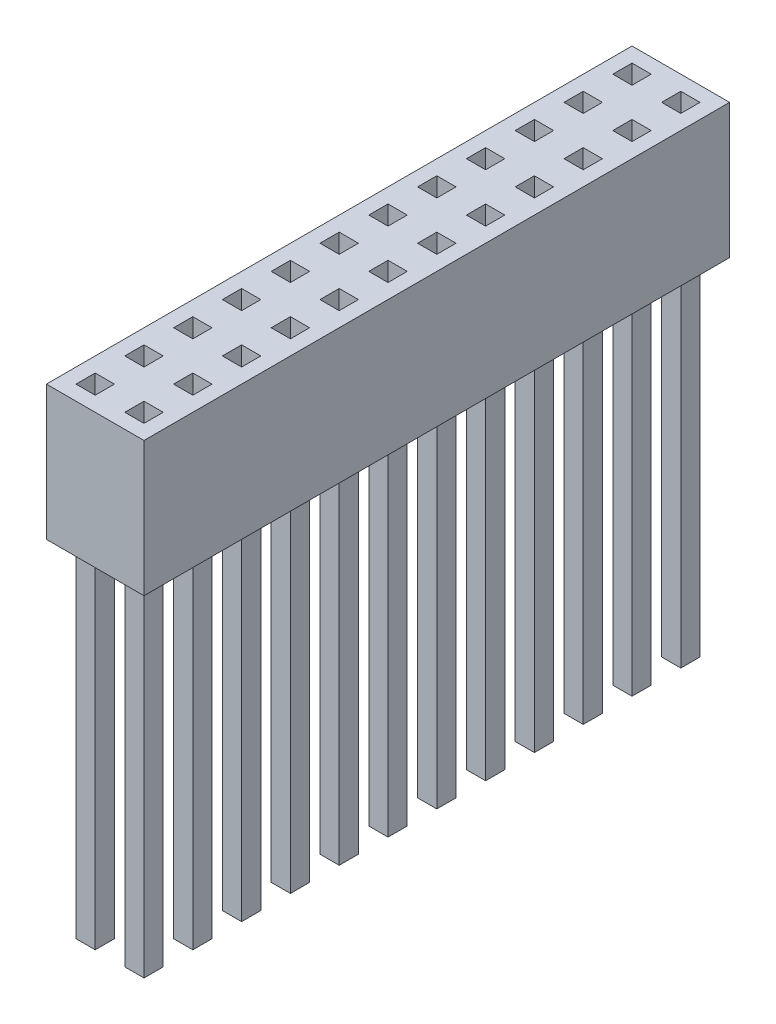
from build123d import *

# Parameters (mm, degrees)
SKETCH_1_W              = 1
SKETCH_1_H              = 1
EXTRUDE_1_DEPTH         = 20
EXTRUDE_1_DEPTH_BACK    = 4
EXTRUDE_1_2_DEPTH       = 20
EXTRUDE_1_2_DEPTH_BACK  = 4
EXTRUDE_1_3_DEPTH       = 20
EXTRUDE_1_3_DEPTH_BACK  = 4
EXTRUDE_1_4_DEPTH       = 20
EXTRUDE_1_4_DEPTH_BACK  = 4
EXTRUDE_1_5_DEPTH       = 20
EXTRUDE_1_5_DEPTH_BACK  = 4
EXTRUDE_1_6_DEPTH       = 20
EXTRUDE_1_6_DEPTH_BACK  = 4
EXTRUDE_1_7_DEPTH       = 20
EXTRUDE_1_7_DEPTH_BACK  = 4
EXTRUDE_1_8_DEPTH       = 20
EXTRUDE_1_8_DEPTH_BACK  = 4
EXTRUDE_1_9_DEPTH       = 20
EXTRUDE_1_9_DEPTH_BACK  = 4
EXTRUDE_1_10_DEPTH      = 20
EXTRUDE_1_10_DEPTH_BACK = 4
EXTRUDE_1_11_DEPTH      = 20
EXTRUDE_1_11_DEPTH_BACK = 4
EXTRUDE_1_12_DEPTH      = 20
EXTRUDE_1_12_DEPTH_BACK = 4
EXTRUDE_1_13_DEPTH      = 20
EXTRUDE_1_13_DEPTH_BACK = 4
EXTRUDE_1_14_DEPTH      = 20
EXTRUDE_1_14_DEPTH_BACK = 4
EXTRUDE_1_15_DEPTH      = 20
EXTRUDE_1_15_DEPTH_BACK = 4
EXTRUDE_1_16_DEPTH      = 20
EXTRUDE_1_16_DEPTH_BACK = 4
EXTRUDE_1_17_DEPTH      = 20
EXTRUDE_1_17_DEPTH_BACK = 4
EXTRUDE_1_18_DEPTH      = 20
EXTRUDE_1_18_DEPTH_BACK = 4
EXTRUDE_1_19_DEPTH      = 20
EXTRUDE_1_19_DEPTH_BACK = 4
EXTRUDE_1_20_DEPTH      = 20
EXTRUDE_1_20_DEPTH_BACK = 4
EXTRUDE_1_21_DEPTH      = 20
EXTRUDE_1_21_DEPTH_BACK = 4
EXTRUDE_1_22_DEPTH      = 20
EXTRUDE_1_22_DEPTH_BACK = 4
EXTRUDE_1_23_DEPTH      = 20
EXTRUDE_1_23_DEPTH_BACK = 4
EXTRUDE_1_24_DEPTH      = 20
EXTRUDE_1_24_DEPTH_BACK = 4
SKETCH_2_W              = 5.08
SKETCH_2_H              = 30.48
SKETCH_2_W_2            = 1
SKETCH_2_H_2            = 1
EXTRUDE_2_DEPTH         = 1
EXTRUDE_2_DEPTH_BACK    = 6


with BuildPart() as part:
    # Эскиз1 → Бобышка-Вытянуть1 (new body, two sides)
    with BuildSketch(Plane(origin=(0, 0, 0), x_dir=(1, 0, 0), z_dir=(0, 1, 0))) as extrude_1_sk:
        with Locations((2.54, 0)):
            Rectangle(SKETCH_1_W, SKETCH_1_H)
    extrude(amount=EXTRUDE_1_DEPTH)
    extrude(extrude_1_sk.sketch, amount=-EXTRUDE_1_DEPTH_BACK)



with BuildPart() as body_2:
    # Эскиз1 → Extrude 1 2 (new body, two sides)
    with BuildSketch(Plane(origin=(0, 0, 0), x_dir=(1, 0, 0), z_dir=(0, 1, 0))) as extrude_1_2_sk:
        Rectangle(SKETCH_1_W, SKETCH_1_H)
    extrude(amount=EXTRUDE_1_2_DEPTH)
    extrude(extrude_1_2_sk.sketch, amount=-EXTRUDE_1_2_DEPTH_BACK)


with BuildPart() as body_3:
    # Эскиз1 → Extrude 1 3 (new body, two sides)
    with BuildSketch(Plane(origin=(0, 0, 0), x_dir=(1, 0, 0), z_dir=(0, 1, 0))) as extrude_1_3_sk:
        with Locations((2.54, 2.54)):
            Rectangle(SKETCH_1_W, SKETCH_1_H)
    extrude(amount=EXTRUDE_1_3_DEPTH)
    extrude(extrude_1_3_sk.sketch, amount=-EXTRUDE_1_3_DEPTH_BACK)


with BuildPart() as body_4:
    # Эскиз1 → Extrude 1 4 (new body, two sides)
    with BuildSketch(Plane(origin=(0, 0, 0), x_dir=(1, 0, 0), z_dir=(0, 1, 0))) as extrude_1_4_sk:
        with Locations((2.54, 5.08)):
            Rectangle(SKETCH_1_W, SKETCH_1_H)
    extrude(amount=EXTRUDE_1_4_DEPTH)
    extrude(extrude_1_4_sk.sketch, amount=-EXTRUDE_1_4_DEPTH_BACK)


with BuildPart() as body_5:
    # Эскиз1 → Extrude 1 5 (new body, two sides)
    with BuildSketch(Plane(origin=(0, 0, 0), x_dir=(1, 0, 0), z_dir=(0, 1, 0))) as extrude_1_5_sk:
        with Locations((2.54, 7.62)):
            Rectangle(SKETCH_1_W, SKETCH_1_H)
    extrude(amount=EXTRUDE_1_5_DEPTH)
    extrude(extrude_1_5_sk.sketch, amount=-EXTRUDE_1_5_DEPTH_BACK)


with BuildPart() as body_6:
    # Эскиз1 → Extrude 1 6 (new body, two sides)
    with BuildSketch(Plane(origin=(0, 0, 0), x_dir=(1, 0, 0), z_dir=(0, 1, 0))) as extrude_1_6_sk:
        with Locations((2.54, 10.16)):
            Rectangle(SKETCH_1_W, SKETCH_1_H)
    extrude(amount=EXTRUDE_1_6_DEPTH)
    extrude(extrude_1_6_sk.sketch, amount=-EXTRUDE_1_6_DEPTH_BACK)


with BuildPart() as body_7:
    # Эскиз1 → Extrude 1 7 (new body, two sides)
    with BuildSketch(Plane(origin=(0, 0, 0), x_dir=(1, 0, 0), z_dir=(0, 1, 0))) as extrude_1_7_sk:
        with Locations((2.54, 12.7)):
            Rectangle(SKETCH_1_W, SKETCH_1_H)
    extrude(amount=EXTRUDE_1_7_DEPTH)
    extrude(extrude_1_7_sk.sketch, amount=-EXTRUDE_1_7_DEPTH_BACK)


with BuildPart() as body_8:
    # Эскиз1 → Extrude 1 8 (new body, two sides)
    with BuildSketch(Plane(origin=(0, 0, 0), x_dir=(1, 0, 0), z_dir=(0, 1, 0))) as extrude_1_8_sk:
        with Locations((2.54, 15.24)):
            Rectangle(SKETCH_1_W, SKETCH_1_H)
    extrude(amount=EXTRUDE_1_8_DEPTH)
    extrude(extrude_1_8_sk.sketch, amount=-EXTRUDE_1_8_DEPTH_BACK)


with BuildPart() as body_9:
    # Эскиз1 → Extrude 1 9 (new body, two sides)
    with BuildSketch(Plane(origin=(0, 0, 0), x_dir=(1, 0, 0), z_dir=(0, 1, 0))) as extrude_1_9_sk:
        with Locations((2.54, 17.78)):
            Rectangle(SKETCH_1_W, SKETCH_1_H)
    extrude(amount=EXTRUDE_1_9_DEPTH)
    extrude(extrude_1_9_sk.sketch, amount=-EXTRUDE_1_9_DEPTH_BACK)


with BuildPart() as body_10:
    # Эскиз1 → Extrude 1 10 (new body, two sides)
    with BuildSketch(Plane(origin=(0, 0, 0), x_dir=(1, 0, 0), z_dir=(0, 1, 0))) as extrude_1_10_sk:
        with Locations((2.54, 20.32)):
            Rectangle(SKETCH_1_W, SKETCH_1_H)
    extrude(amount=EXTRUDE_1_10_DEPTH)
    extrude(extrude_1_10_sk.sketch, amount=-EXTRUDE_1_10_DEPTH_BACK)


with BuildPart() as body_11:
    # Эскиз1 → Extrude 1 11 (new body, two sides)
    with BuildSketch(Plane(origin=(0, 0, 0), x_dir=(1, 0, 0), z_dir=(0, 1, 0))) as extrude_1_11_sk:
        with Locations((2.54, 22.86)):
            Rectangle(SKETCH_1_W, SKETCH_1_H)
    extrude(amount=EXTRUDE_1_11_DEPTH)
    extrude(extrude_1_11_sk.sketch, amount=-EXTRUDE_1_11_DEPTH_BACK)


with BuildPart() as body_12:
    # Эскиз1 → Extrude 1 12 (new body, two sides)
    with BuildSketch(Plane(origin=(0, 0, 0), x_dir=(1, 0, 0), z_dir=(0, 1, 0))) as extrude_1_12_sk:
        with Locations((2.54, 25.4)):
            Rectangle(SKETCH_1_W, SKETCH_1_H)
    extrude(amount=EXTRUDE_1_12_DEPTH)
    extrude(extrude_1_12_sk.sketch, amount=-EXTRUDE_1_12_DEPTH_BACK)


with BuildPart() as body_13:
    # Эскиз1 → Extrude 1 13 (new body, two sides)
    with BuildSketch(Plane(origin=(0, 0, 0), x_dir=(1, 0, 0), z_dir=(0, 1, 0))) as extrude_1_13_sk:
        with Locations((2.54, 27.94)):
            Rectangle(SKETCH_1_W, SKETCH_1_H)
    extrude(amount=EXTRUDE_1_13_DEPTH)
    extrude(extrude_1_13_sk.sketch, amount=-EXTRUDE_1_13_DEPTH_BACK)


with BuildPart() as body_14:
    # Эскиз1 → Extrude 1 14 (new body, two sides)
    with BuildSketch(Plane(origin=(0, 0, 0), x_dir=(1, 0, 0), z_dir=(0, 1, 0))) as extrude_1_14_sk:
        with Locations((0, 2.54)):
            Rectangle(SKETCH_1_W, SKETCH_1_H)
    extrude(amount=EXTRUDE_1_14_DEPTH)
    extrude(extrude_1_14_sk.sketch, amount=-EXTRUDE_1_14_DEPTH_BACK)


with BuildPart() as body_15:
    # Эскиз1 → Extrude 1 15 (new body, two sides)
    with BuildSketch(Plane(origin=(0, 0, 0), x_dir=(1, 0, 0), z_dir=(0, 1, 0))) as extrude_1_15_sk:
        with Locations((0, 5.08)):
            Rectangle(SKETCH_1_W, SKETCH_1_H)
    extrude(amount=EXTRUDE_1_15_DEPTH)
    extrude(extrude_1_15_sk.sketch, amount=-EXTRUDE_1_15_DEPTH_BACK)


with BuildPart() as body_16:
    # Эскиз1 → Extrude 1 16 (new body, two sides)
    with BuildSketch(Plane(origin=(0, 0, 0), x_dir=(1, 0, 0), z_dir=(0, 1, 0))) as extrude_1_16_sk:
        with Locations((0, 7.62)):
            Rectangle(SKETCH_1_W, SKETCH_1_H)
    extrude(amount=EXTRUDE_1_16_DEPTH)
    extrude(extrude_1_16_sk.sketch, amount=-EXTRUDE_1_16_DEPTH_BACK)


with BuildPart() as body_17:
    # Эскиз1 → Extrude 1 17 (new body, two sides)
    with BuildSketch(Plane(origin=(0, 0, 0), x_dir=(1, 0, 0), z_dir=(0, 1, 0))) as extrude_1_17_sk:
        with Locations((0, 10.16)):
            Rectangle(SKETCH_1_W, SKETCH_1_H)
    extrude(amount=EXTRUDE_1_17_DEPTH)
    extrude(extrude_1_17_sk.sketch, amount=-EXTRUDE_1_17_DEPTH_BACK)


with BuildPart() as body_18:
    # Эскиз1 → Extrude 1 18 (new body, two sides)
    with BuildSketch(Plane(origin=(0, 0, 0), x_dir=(1, 0, 0), z_dir=(0, 1, 0))) as extrude_1_18_sk:
        with Locations((0, 12.7)):
            Rectangle(SKETCH_1_W, SKETCH_1_H)
    extrude(amount=EXTRUDE_1_18_DEPTH)
    extrude(extrude_1_18_sk.sketch, amount=-EXTRUDE_1_18_DEPTH_BACK)


with BuildPart() as body_19:
    # Эскиз1 → Extrude 1 19 (new body, two sides)
    with BuildSketch(Plane(origin=(0, 0, 0), x_dir=(1, 0, 0), z_dir=(0, 1, 0))) as extrude_1_19_sk:
        with Locations((0, 15.24)):
            Rectangle(SKETCH_1_W, SKETCH_1_H)
    extrude(amount=EXTRUDE_1_19_DEPTH)
    extrude(extrude_1_19_sk.sketch, amount=-EXTRUDE_1_19_DEPTH_BACK)


with BuildPart() as body_20:
    # Эскиз1 → Extrude 1 20 (new body, two sides)
    with BuildSketch(Plane(origin=(0, 0, 0), x_dir=(1, 0, 0), z_dir=(0, 1, 0))) as extrude_1_20_sk:
        with Locations((0, 17.78)):
            Rectangle(SKETCH_1_W, SKETCH_1_H)
    extrude(amount=EXTRUDE_1_20_DEPTH)
    extrude(extrude_1_20_sk.sketch, amount=-EXTRUDE_1_20_DEPTH_BACK)


with BuildPart() as body_21:
    # Эскиз1 → Extrude 1 21 (new body, two sides)
    with BuildSketch(Plane(origin=(0, 0, 0), x_dir=(1, 0, 0), z_dir=(0, 1, 0))) as extrude_1_21_sk:
        with Locations((0, 20.32)):
            Rectangle(SKETCH_1_W, SKETCH_1_H)
    extrude(amount=EXTRUDE_1_21_DEPTH)
    extrude(extrude_1_21_sk.sketch, amount=-EXTRUDE_1_21_DEPTH_BACK)


with BuildPart() as body_22:
    # Эскиз1 → Extrude 1 22 (new body, two sides)
    with BuildSketch(Plane(origin=(0, 0, 0), x_dir=(1, 0, 0), z_dir=(0, 1, 0))) as extrude_1_22_sk:
        with Locations((0, 22.86)):
            Rectangle(SKETCH_1_W, SKETCH_1_H)
    extrude(amount=EXTRUDE_1_22_DEPTH)
    extrude(extrude_1_22_sk.sketch, amount=-EXTRUDE_1_22_DEPTH_BACK)


with BuildPart() as body_23:
    # Эскиз1 → Extrude 1 23 (new body, two sides)
    with BuildSketch(Plane(origin=(0, 0, 0), x_dir=(1, 0, 0), z_dir=(0, 1, 0))) as extrude_1_23_sk:
        with Locations((0, 25.4)):
            Rectangle(SKETCH_1_W, SKETCH_1_H)
    extrude(amount=EXTRUDE_1_23_DEPTH)
    extrude(extrude_1_23_sk.sketch, amount=-EXTRUDE_1_23_DEPTH_BACK)


with BuildPart() as body_24:
    # Эскиз1 → Extrude 1 24 (new body, two sides)
    with BuildSketch(Plane(origin=(0, 0, 0), x_dir=(1, 0, 0), z_dir=(0, 1, 0))) as extrude_1_24_sk:
        with Locations((0, 27.94)):
            Rectangle(SKETCH_1_W, SKETCH_1_H)
    extrude(amount=EXTRUDE_1_24_DEPTH)
    extrude(extrude_1_24_sk.sketch, amount=-EXTRUDE_1_24_DEPTH_BACK)


with BuildPart() as part_1:
    add(part.part)

    add(body_2.part)  # Бобышка-Вытянуть2 merges body 2

    add(body_3.part)  # Бобышка-Вытянуть2 merges body 3

    add(body_4.part)  # Бобышка-Вытянуть2 merges body 4

    add(body_5.part)  # Бобышка-Вытянуть2 merges body 5

    add(body_6.part)  # Бобышка-Вытянуть2 merges body 6

    add(body_7.part)  # Бобышка-Вытянуть2 merges body 7

    add(body_8.part)  # Бобышка-Вытянуть2 merges body 8

    add(body_9.part)  # Бобышка-Вытянуть2 merges body 9

    add(body_10.part)  # Бобышка-Вытянуть2 merges body 10

    add(body_11.part)  # Бобышка-Вытянуть2 merges body 11

    add(body_12.part)  # Бобышка-Вытянуть2 merges body 12

    add(body_13.part)  # Бобышка-Вытянуть2 merges body 13

    add(body_14.part)  # Бобышка-Вытянуть2 merges body 14

    add(body_15.part)  # Бобышка-Вытянуть2 merges body 15

    add(body_16.part)  # Бобышка-Вытянуть2 merges body 16

    add(body_17.part)  # Бобышка-Вытянуть2 merges body 17

    add(body_18.part)  # Бобышка-Вытянуть2 merges body 18

    add(body_19.part)  # Бобышка-Вытянуть2 merges body 19

    add(body_20.part)  # Бобышка-Вытянуть2 merges body 20

    add(body_21.part)  # Бобышка-Вытянуть2 merges body 21

    add(body_22.part)  # Бобышка-Вытянуть2 merges body 22

    add(body_23.part)  # Бобышка-Вытянуть2 merges body 23

    add(body_24.part)  # Бобышка-Вытянуть2 merges body 24
    # Эскиз2 → Бобышка-Вытянуть2 (add, two sides)
    with BuildSketch(Plane(origin=(0, 20, 0), x_dir=(1, 0, 0), z_dir=(0, 1, 0))) as extrude_2_sk:
        with Locations((1.27, 13.97)):
            Rectangle(SKETCH_2_W, SKETCH_2_H)
        with Locations((2.54, 0)):
            Rectangle(SKETCH_2_W_2, SKETCH_2_H_2, mode=Mode.SUBTRACT)
        Rectangle(SKETCH_2_W_2, SKETCH_2_H_2, mode=Mode.SUBTRACT)
        with Locations((2.54, 2.54)):
            Rectangle(SKETCH_2_W_2, SKETCH_2_H_2, mode=Mode.SUBTRACT)
        with Locations((2.54, 5.08)):
            Rectangle(SKETCH_2_W_2, SKETCH_2_H_2, mode=Mode.SUBTRACT)
        with Locations((2.54, 7.62)):
            Rectangle(SKETCH_2_W_2, SKETCH_2_H_2, mode=Mode.SUBTRACT)
        with Locations((2.54, 10.16)):
            Rectangle(SKETCH_2_W_2, SKETCH_2_H_2, mode=Mode.SUBTRACT)
        with Locations((2.54, 12.7)):
            Rectangle(SKETCH_2_W_2, SKETCH_2_H_2, mode=Mode.SUBTRACT)
        with Locations((2.54, 15.24)):
            Rectangle(SKETCH_2_W_2, SKETCH_2_H_2, mode=Mode.SUBTRACT)
        with Locations((2.54, 17.78)):
            Rectangle(SKETCH_2_W_2, SKETCH_2_H_2, mode=Mode.SUBTRACT)
        with Locations((2.54, 20.32)):
            Rectangle(SKETCH_2_W_2, SKETCH_2_H_2, mode=Mode.SUBTRACT)
        with Locations((2.54, 22.86)):
            Rectangle(SKETCH_2_W_2, SKETCH_2_H_2, mode=Mode.SUBTRACT)
        with Locations((2.54, 25.4)):
            Rectangle(SKETCH_2_W_2, SKETCH_2_H_2, mode=Mode.SUBTRACT)
        with Locations((2.54, 27.94)):
            Rectangle(SKETCH_2_W_2, SKETCH_2_H_2, mode=Mode.SUBTRACT)
        with Locations((0, 2.54)):
            Rectangle(SKETCH_2_W_2, SKETCH_2_H_2, mode=Mode.SUBTRACT)
        with Locations((0, 5.08)):
            Rectangle(SKETCH_2_W_2, SKETCH_2_H_2, mode=Mode.SUBTRACT)
        with Locations((0, 7.62)):
            Rectangle(SKETCH_2_W_2, SKETCH_2_H_2, mode=Mode.SUBTRACT)
        with Locations((0, 10.16)):
            Rectangle(SKETCH_2_W_2, SKETCH_2_H_2, mode=Mode.SUBTRACT)
        with Locations((0, 12.7)):
            Rectangle(SKETCH_2_W_2, SKETCH_2_H_2, mode=Mode.SUBTRACT)
        with Locations((0, 15.24)):
            Rectangle(SKETCH_2_W_2, SKETCH_2_H_2, mode=Mode.SUBTRACT)
        with Locations((0, 17.78)):
            Rectangle(SKETCH_2_W_2, SKETCH_2_H_2, mode=Mode.SUBTRACT)
        with Locations((0, 20.32)):
            Rectangle(SKETCH_2_W_2, SKETCH_2_H_2, mode=Mode.SUBTRACT)
        with Locations((0, 22.86)):
            Rectangle(SKETCH_2_W_2, SKETCH_2_H_2, mode=Mode.SUBTRACT)
        with Locations((0, 25.4)):
            Rectangle(SKETCH_2_W_2, SKETCH_2_H_2, mode=Mode.SUBTRACT)
        with Locations((0, 27.94)):
            Rectangle(SKETCH_2_W_2, SKETCH_2_H_2, mode=Mode.SUBTRACT)
    extrude(amount=EXTRUDE_2_DEPTH)
    extrude(extrude_2_sk.sketch, amount=-EXTRUDE_2_DEPTH_BACK)


solid = part_1.part
